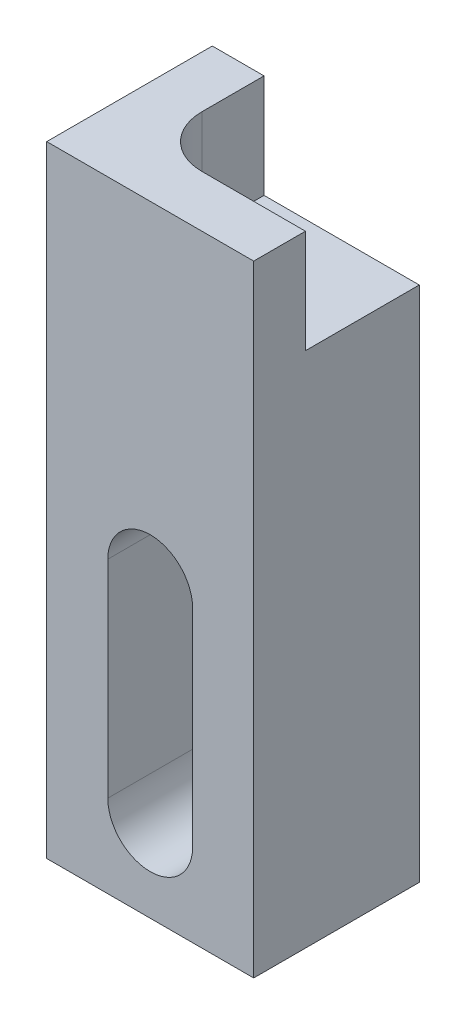
from build123d import *

# Parameters (mm, degrees)
SKETCH1_W           = 20
SKETCH1_H           = 60
BOSS_EXTRUDE1_DEPTH = 8
CUT_EXTRUDE1_DEPTH  = 10


with BuildPart() as part:
    # Sketch1 → Boss-Extrude1 (new body, symmetric)
    with BuildSketch(Plane.XY):
        with Locations((0, 30)):
            Rectangle(SKETCH1_W, SKETCH1_H)
        with BuildLine():
            Line((4.1, 28), (4.1, 8))
            ThreePointArc((4.1, 8), (0, 3.9), (-4.1, 8))
            Line((-4.1, 8), (-4.1, 28))
            ThreePointArc((-4.1, 28), (0, 32.1), (4.1, 28))
        make_face(mode=Mode.SUBTRACT)
    extrude(amount=BOSS_EXTRUDE1_DEPTH, both=True)

    # Sketch2 → Cut-Extrude1 (cut)
    with BuildSketch(Plane(origin=(0, 60, 0), x_dir=(1, 0, 0), z_dir=(0, 1, 0))):
        with BuildLine():
            Line((10, -3), (0, -3))
            ThreePointArc((0, -3), (-3.535533906, -1.535533906), (-5, 2))
            Line((-5, 2), (-5, 8))
            Line((-5, 8), (10, 8))
            Line((10, 8), (10, -3))
        make_face()
    extrude(amount=-CUT_EXTRUDE1_DEPTH, mode=Mode.SUBTRACT)


solid = part.part
